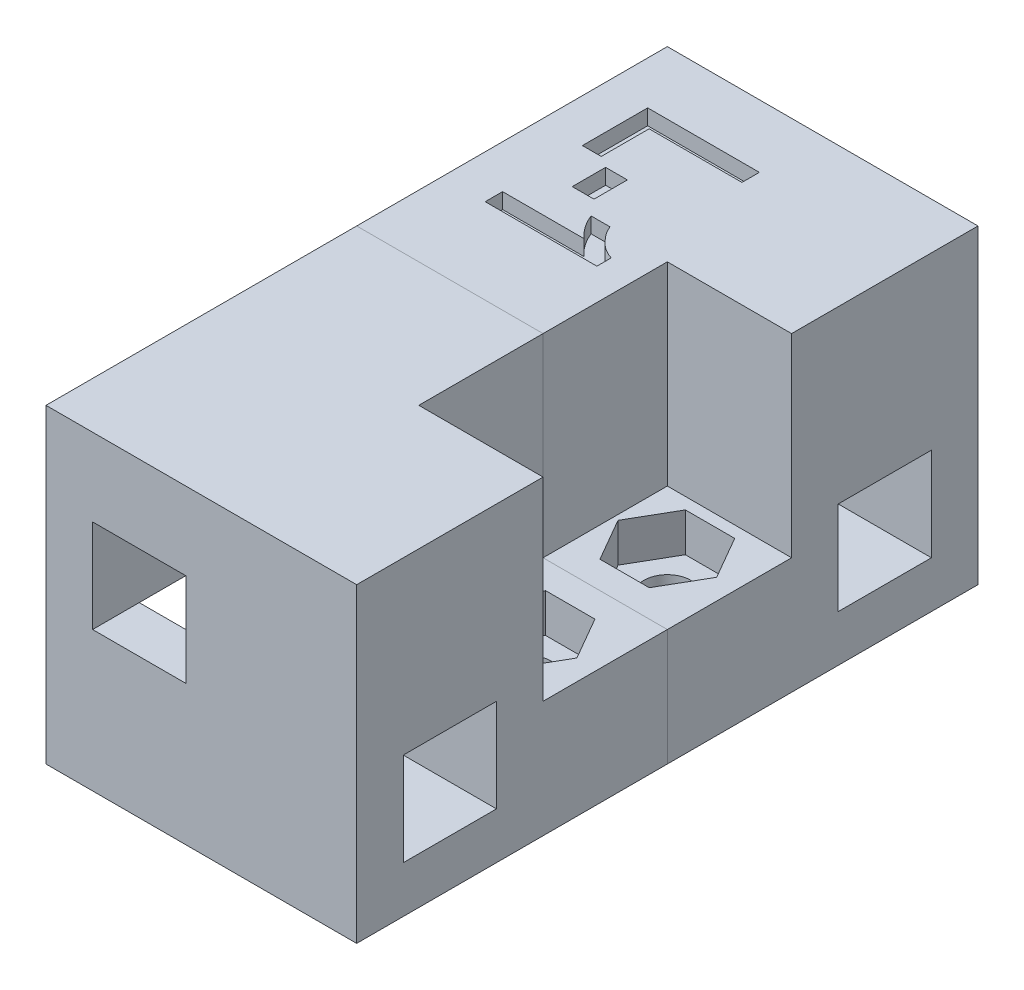
from build123d import *

# Parameters (mm, degrees)
RESSALTO_EXTRUS_O1_DEPTH = 20
ESBO_O2_W                = 6
ESBO_O2_H                = 6
CORTE_EXTRUS_O1_DEPTH    = 20
ESBO_O3_W                = 6
ESBO_O3_H                = 6
CORTE_EXTRUS_O2_DEPTH    = 20
ESBO_O1_3_W              = 8
ESBO_O1_3_H              = 8
RESSALTO_EXTRUS_O2_DEPTH = 7.5
CORTE_EXTRUS_O3_DEPTH    = 2.5
ESBO_O4_3_R              = 1.5
CORTE_EXTRUS_O4_DEPTH    = 31.923292192
ESBO_O7_W                = 1.400901101
ESBO_O7_H                = 2.148048355
CORTE_EXTRUS_O5_DEPTH    = 1


with BuildPart() as part:
    # Esboço1 → Ressalto-extrusão1 (new body)
    with BuildSketch(Plane(origin=(0, 0, 0), x_dir=(1, 0, 0), z_dir=(0, 1, 0))):
        Polygon((12, 12), (12, 20), (0, 20), (0, 0), (20, 0), (20, 12), align=None)
    extrude(amount=RESSALTO_EXTRUS_O1_DEPTH)

    # Esboço2 → Corte-extrusão1 (cut)
    with BuildSketch(Plane(origin=(20, 0, 0), x_dir=(0, 0, -1), z_dir=(1, 0, 0))):
        with Locations((6, 6)):
            Rectangle(ESBO_O2_W, ESBO_O2_H)
    extrude(amount=-CORTE_EXTRUS_O1_DEPTH, mode=Mode.SUBTRACT)

    # Esboço3 → Corte-extrusão2 (cut)
    with BuildSketch(Plane(origin=(0, 0, -20), x_dir=(-1, 0, 0), z_dir=(0, 0, -1))):
        with Locations((-6, 12)):
            Rectangle(ESBO_O3_W, ESBO_O3_H)
    extrude(amount=-CORTE_EXTRUS_O2_DEPTH, mode=Mode.SUBTRACT)

    # Esboço1<3> → Ressalto-extrusão2 (add)
    with BuildSketch(Plane(origin=(0, 0, 0), x_dir=(1, 0, 0), z_dir=(0, 1, 0))):
        with Locations((16, 16)):
            Rectangle(ESBO_O1_3_W, ESBO_O1_3_H)
    extrude(amount=RESSALTO_EXTRUS_O2_DEPTH)

    # Esboço4 → Corte-extrusão3 (cut)
    with BuildSketch(Plane(origin=(0, 7.5, 0), x_dir=(1, 0, 0), z_dir=(0, 1, 0))):
        Polygon((13.91228676, 18.25), (12.324573519, 15.5), (13.91228676, 12.75), (17.08771324, 12.75), (18.675426481, 15.5), (17.08771324, 18.25), align=None)
    extrude(amount=-CORTE_EXTRUS_O3_DEPTH, mode=Mode.SUBTRACT)

    # Esboço4<3> → Corte-extrusão4 (cut, through all)
    with BuildSketch(Plane(origin=(0, 7.5, 0), x_dir=(1, 0, 0), z_dir=(0, 1, 0))):
        with Locations((15.5, 15.5)):
            Circle(ESBO_O4_3_R)
    extrude(amount=-CORTE_EXTRUS_O4_DEPTH, mode=Mode.SUBTRACT)


with BuildPart() as body_2:
    # Espelhar1: mirrored copy
    add(part.part.mirror(Plane(origin=(-12.141421356, 20, -20), x_dir=(1, 0, 0), z_dir=(0, 0, -1))))

    # Esboço7 → Corte-extrusão5 (cut)
    with BuildSketch(Plane(origin=(0, 20, 0), x_dir=(1, 0, 0), z_dir=(0, 1, 0))):
        Polygon((2.783424816, 35.950756168), (9.974717134, 35.950756168), (9.974717134, 34.830035287), (3.997539104, 34.830035287), (3.997539104, 31.748052865), (2.783424816, 31.748052865), align=None)
        with Locations((5.445136908, 30.207061655)):
            Rectangle(ESBO_O7_W, ESBO_O7_H)
        with BuildLine():
            Line((2.783424816, 25.490694615), (2.783424816, 26.611415495))
            Line((2.783424816, 26.611415495), (8.013455593, 26.611415495))
            add(Edge.make_bspline(
                [(8.013455593, 26.611415495), (7.956411457, 26.665764983), (7.843279583, 26.773552739), (7.685471783, 26.945128313), (7.539228038, 27.122576834), (7.406822909, 27.308171919), (7.281823141, 27.496696655), (7.170922859, 27.693520375), (7.07110991, 27.896079573), (7.014475836, 28.035782738), (6.986128119, 28.105710003)],
                knots=[0, 0, 0, 0, 1.033503725, 2.049679824, 3.056413032, 4.048331092, 5.039591953, 6.022745765, 7.010301735, 8, 8, 8, 8], degree=3))
            Line((6.986128119, 28.105710003), (8.200242406, 28.105710003))
            add(Edge.make_bspline(
                [(8.200242406, 28.105710003), (8.236066427, 28.025116526), (8.310650014, 27.857325464), (8.460324288, 27.611800786), (8.648310553, 27.363786483), (8.827695235, 27.157127828), (8.987454389, 26.996120291), (9.11521435, 26.883747501), (9.246337495, 26.779186126), (9.383497662, 26.686533309), (9.524626153, 26.602348603), (9.670003799, 26.528562753), (9.819683418, 26.462912887), (9.922856549, 26.428695038), (9.974717134, 26.411495234)],
                knots=[0, 0, 0, 0, 1.255971001, 2.614860626, 4.085896947, 5.687542932, 6.511057959, 7.316458574, 8.111137054, 8.899470754, 9.673439434, 10.45161887, 11.221697062, 12, 12, 12, 12], degree=3))
            Line((9.974717134, 26.411495234), (9.974717134, 25.490694615))
            Line((9.974717134, 25.490694615), (2.783424816, 25.490694615))
        make_face()
    extrude(amount=-CORTE_EXTRUS_O5_DEPTH, mode=Mode.SUBTRACT)


solid = Compound([part.part, body_2.part])
